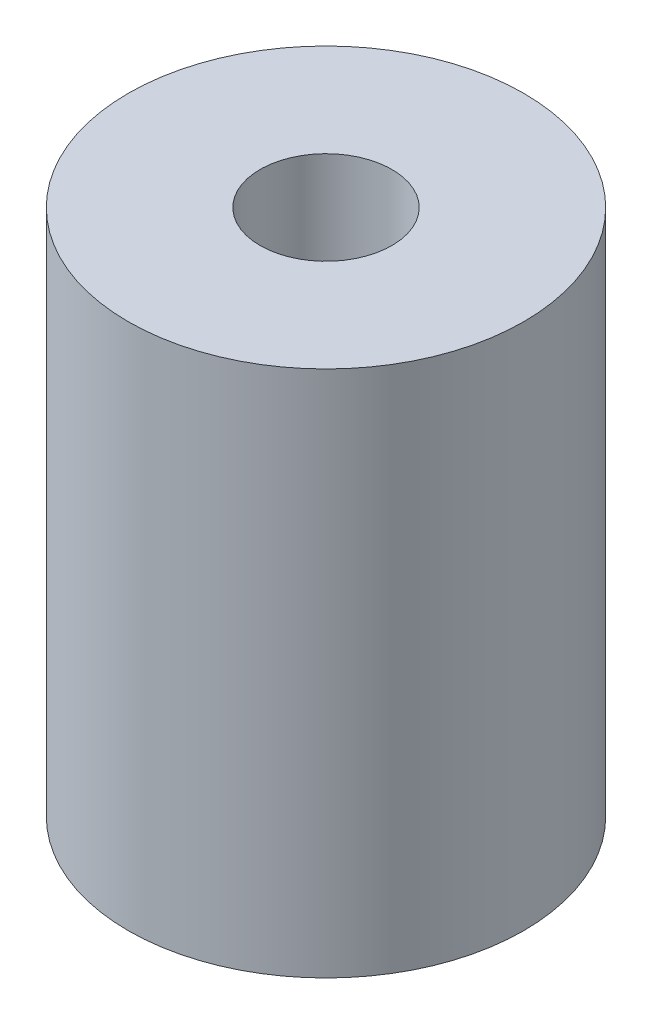
from build123d import *

# Parameters (mm, degrees)
SKETCH1_R           = 9.525
SKETCH1_R_2         = 3.175
BOSS_EXTRUDE1_DEPTH = 25.4


with BuildPart() as part:
    # Sketch1 → Boss-Extrude1 (new body)
    with BuildSketch(Plane(origin=(0, 0, 0), x_dir=(1, 0, 0), z_dir=(0, 1, 0))):
        Circle(SKETCH1_R)
        Circle(SKETCH1_R_2, mode=Mode.SUBTRACT)
    extrude(amount=BOSS_EXTRUDE1_DEPTH)


solid = part.part
